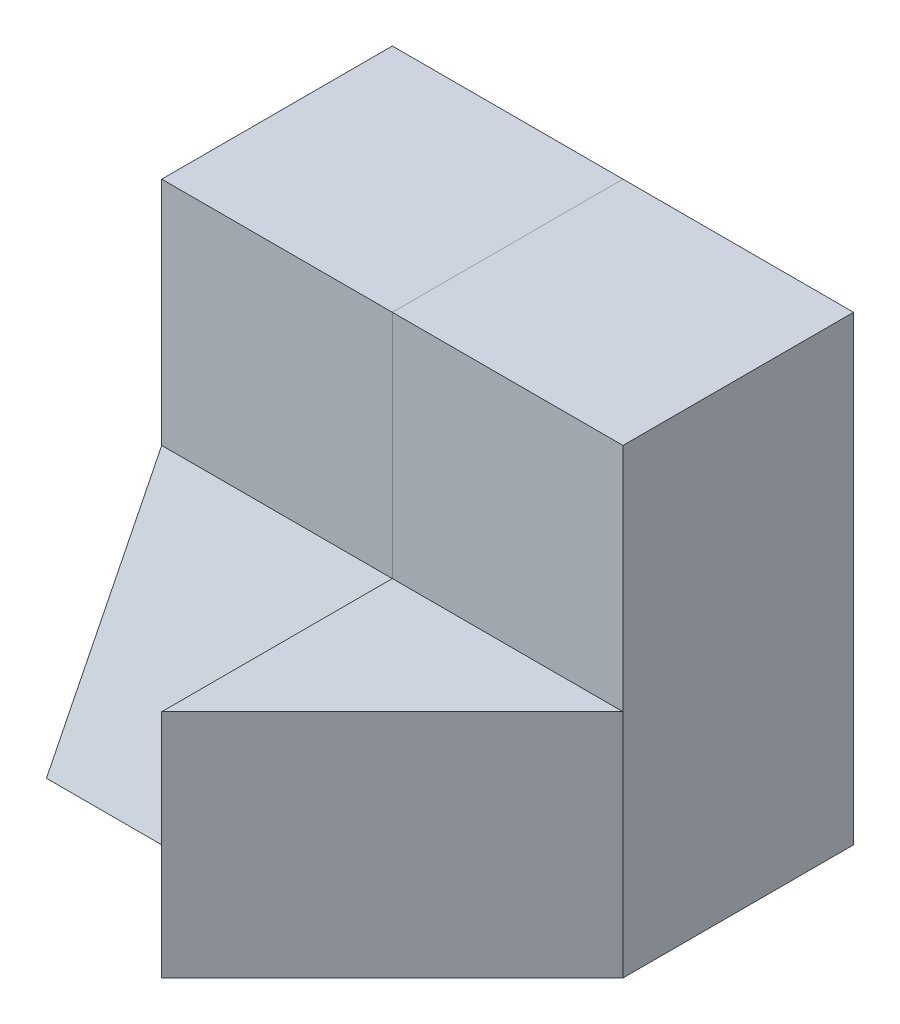
from build123d import *

# Parameters (mm, degrees)
SKETCH1_W           = 40
SKETCH1_H           = 40
BOSS_EXTRUDE1_DEPTH = 40
SKETCH2_W           = 20
SKETCH2_H           = 10
CUT_EXTRUDE1_DEPTH  = 40
SKETCH3_W           = 20
SKETCH3_H           = 20
CUT_EXTRUDE2_DEPTH  = 40
SKETCH5_W           = 20
SKETCH5_H           = 20
CUT_EXTRUDE3_DEPTH  = 10
SKETCH7_W           = 20
SKETCH7_H           = 20
BOSS_EXTRUDE2_DEPTH = 10
SKETCH8_W           = 20
SKETCH8_H           = 20
BOSS_EXTRUDE3_DEPTH = 10
CUT_EXTRUDE10_DEPTH = 27
CUT_EXTRUDE12_DEPTH = 20
SKETCH12_W          = 20
SKETCH12_H          = 20
BOSS_EXTRUDE4_DEPTH = 0.0001
SKETCH14_W          = 9.999
SKETCH14_H          = 19.999
CUT_EXTRUDE19_DEPTH = 20.0001
CUT_EXTRUDE20_DEPTH = 20.0001
CUT_EXTRUDE21_DEPTH = 0.0001


with BuildPart() as part:
    # Sketch1 → Boss-Extrude1 (new body)
    with BuildSketch(Plane.XY):
        with Locations((20, 20)):
            Rectangle(SKETCH1_W, SKETCH1_H)
    extrude(amount=BOSS_EXTRUDE1_DEPTH)

    # Sketch2 → Cut-Extrude1 (cut)
    with BuildSketch(Plane(origin=(0, 40, 0), x_dir=(1, 0, 0), z_dir=(0, 1, 0))):
        with Locations((10, -35)):
            Rectangle(SKETCH2_W, SKETCH2_H)
    extrude(amount=-CUT_EXTRUDE1_DEPTH, mode=Mode.SUBTRACT)

    # Sketch3 → Cut-Extrude2 (cut)
    with BuildSketch(Plane.ZY):
        with Locations((30, 30)):
            Rectangle(SKETCH3_W, SKETCH3_H)
    extrude(amount=-CUT_EXTRUDE2_DEPTH, mode=Mode.SUBTRACT)

    # Sketch5 → Cut-Extrude3 (cut)
    with BuildSketch(Plane(origin=(40, 0, 0), x_dir=(0, 0, -1), z_dir=(1, 0, 0))):
        with Locations((-30, 10)):
            Rectangle(SKETCH5_W, SKETCH5_H)
    extrude(amount=-CUT_EXTRUDE3_DEPTH, mode=Mode.SUBTRACT)

    # Sketch7 → Boss-Extrude2 (add)
    with BuildSketch(Plane.XY.offset(20)):
        with Locations((10, 30)):
            Rectangle(SKETCH7_W, SKETCH7_H)
    extrude(amount=BOSS_EXTRUDE2_DEPTH)

    # Sketch8 → Boss-Extrude3 (add)
    with BuildSketch(Plane(origin=(30, 0, 0), x_dir=(0, 0, -1), z_dir=(1, 0, 0))):
        with Locations((-30, 10)):
            Rectangle(SKETCH8_W, SKETCH8_H)
    extrude(amount=BOSS_EXTRUDE3_DEPTH)

    # Sketch10 → Cut-Extrude10 (cut)
    with BuildSketch(Plane(origin=(0, 20, 0), x_dir=(1, 0, 0), z_dir=(0, 1, 0))):
        Polygon((20, -40), (40, -20), (40, -40), align=None)
    extrude(amount=-CUT_EXTRUDE10_DEPTH, mode=Mode.SUBTRACT)

    # Sketch11 → Cut-Extrude12 (cut)
    with BuildSketch(Plane.ZY):
        Polygon((10.0001, 39.9999), (0.0001, 0), (30.0001, 0), align=None)
    extrude(amount=-CUT_EXTRUDE12_DEPTH, mode=Mode.SUBTRACT)

    # Sketch12 → Boss-Extrude4 (add)
    with BuildSketch(Plane(origin=(0, 40, 0), x_dir=(1, 0, 0), z_dir=(0, 1, 0))):
        with Locations((30, -10)):
            Rectangle(SKETCH12_W, SKETCH12_H)
    extrude(amount=BOSS_EXTRUDE4_DEPTH)

    # Sketch14 → Cut-Extrude19 (cut)
    with BuildSketch(Plane.ZY):
        with Locations((25.0005, 30.0005)):
            Rectangle(SKETCH14_W, SKETCH14_H)
    extrude(amount=-CUT_EXTRUDE19_DEPTH, mode=Mode.SUBTRACT)

    # Sketch15 → Cut-Extrude20 (cut)
    with BuildSketch(Plane.ZY):
        Polygon((20.001, 20.001), (30, 20.001), (30, 0.0002), align=None)
    extrude(amount=-CUT_EXTRUDE20_DEPTH, mode=Mode.SUBTRACT)

    # Sketch16 → Cut-Extrude21 (cut)
    with BuildSketch(Plane.ZY.offset(-20)):
        Polygon((40, 20), (20.001, 20.001), (30, 0.0002), (40, 0), align=None)
    extrude(amount=-CUT_EXTRUDE21_DEPTH, mode=Mode.SUBTRACT)


solid = part.part
